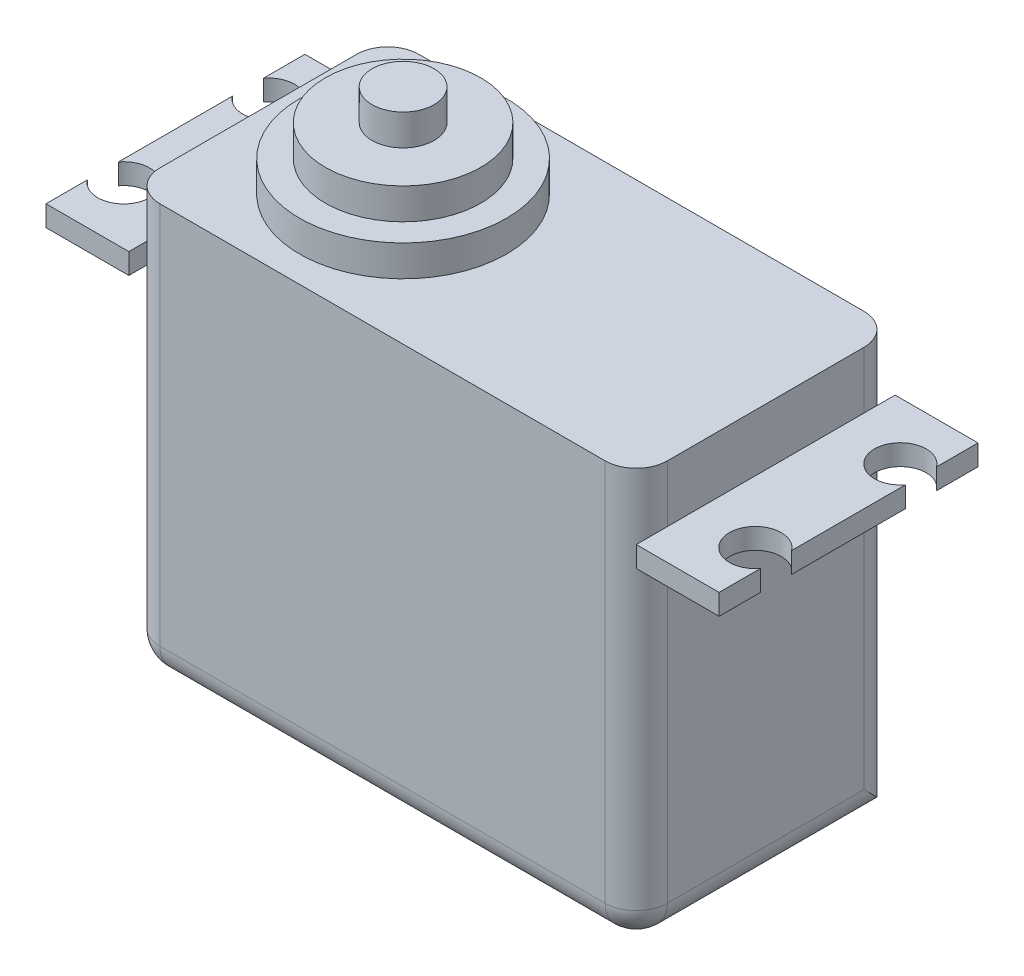
from build123d import *

# Parameters (mm, degrees)
SKETCH1_W           = 49
SKETCH1_H           = 40
BOSS_EXTRUDE1_DEPTH = 25
SKETCH4_R           = 10
BOSS_EXTRUDE2_DEPTH = 3
SKETCH5_R           = 7.5
BOSS_EXTRUDE3_DEPTH = 3
SKETCH6_R           = 3
BOSS_EXTRUDE4_DEPTH = 3
FILLET1_R           = 3
BOSS_EXTRUDE5_DEPTH = 2


with BuildPart() as part:
    # Sketch1 → Boss-Extrude1 (new body)
    with BuildSketch(Plane.XY):
        Rectangle(SKETCH1_W, SKETCH1_H)
    extrude(amount=BOSS_EXTRUDE1_DEPTH)

    # Sketch4 → Boss-Extrude2 (add)
    with BuildSketch(Plane(origin=(0, 20, 0), x_dir=(1, 0, 0), z_dir=(0, 1, 0))):
        with Locations((-10.548196044, -12.468792319)):
            Circle(SKETCH4_R)
    extrude(amount=BOSS_EXTRUDE2_DEPTH)

    # Sketch5 → Boss-Extrude3 (add)
    with BuildSketch(Plane(origin=(0, 23, 0), x_dir=(1, 0, 0), z_dir=(0, 1, 0))):
        with Locations((-10.548196044, -12.468792319)):
            Circle(SKETCH5_R)
    extrude(amount=BOSS_EXTRUDE3_DEPTH)

    # Sketch6 → Boss-Extrude4 (add)
    with BuildSketch(Plane(origin=(0, 26, 0), x_dir=(1, 0, 0), z_dir=(0, 1, 0))):
        with Locations((-10.548196044, -12.468792319)):
            Circle(SKETCH6_R)
    extrude(amount=BOSS_EXTRUDE4_DEPTH)

    # Fillet1
    fillet1_edges = [part.edges().sort_by_distance(p)[0] for p in [
        (24.5, 0, 25),
        (-24.5, 0, 25),
        (24.5, 0, 0),
        (-24.5, 0, 0),
        (0, -20, 25),
        (24.5, -20, 12.5),
        (-24.5, -20, 12.5),
    ]]
    fillet(fillet1_edges, radius=FILLET1_R)

    # Sketch7 → Boss-Extrude5 (add)
    with BuildSketch(Plane(origin=(0, 14.5, 0), x_dir=(1, 0, 0), z_dir=(0, 1, 0))):
        with BuildLine():
            Line((-24.5, 0), (-32.5, 0))
            Line((-32.5, 0), (-32.5, -4))
            ThreePointArc((-32.5, -4), (-28, -5.5), (-32.5, -7))
            Line((-32.5, -7), (-32.5, -18))
            ThreePointArc((-32.5, -18), (-28, -19.5), (-32.5, -21))
            Line((-32.5, -21), (-32.5, -25))
            Line((-32.5, -25), (-24.5, -25))
            Line((-24.5, -25), (-24.5, 0))
        make_face()
        with BuildLine():
            Line((24.5, 0), (24.5, -25))
            Line((24.5, -25), (32.5, -25))
            Line((32.5, -25), (32.5, -21))
            ThreePointArc((32.5, -21), (28, -19.5), (32.5, -18))
            Line((32.5, -18), (32.5, -7))
            ThreePointArc((32.5, -7), (28, -5.5), (32.5, -4))
            Line((32.5, -4), (32.5, 0))
            Line((32.5, 0), (24.5, 0))
        make_face()
    extrude(amount=-BOSS_EXTRUDE5_DEPTH)


solid = part.part
